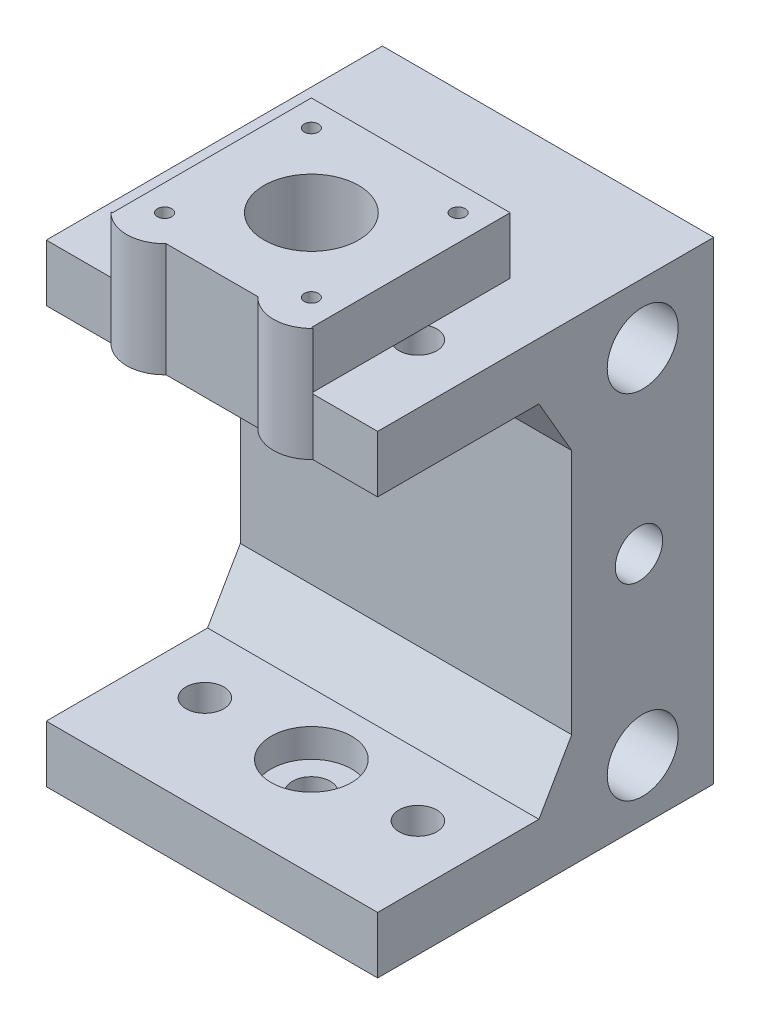
from build123d import *

# Parameters (mm, degrees)
BOSS_EXTRUDE1_DEPTH     = 35
SKETCH2_R               = 4
CUT_EXTRUDE1_DEPTH      = 101
SKETCH3_R               = 7.5
SKETCH3_R_2             = 5
CUT_EXTRUDE2_DEPTH      = 1
CUT_EXTRUDE2_DEPTH_BACK = 71
CHAMFER1_SIZE           = 12
CHAMFER1_SIZE2          = 6.92820323
CHAMFER2_SIZE           = 12
CHAMFER2_SIZE2          = 6.92820323
SKETCH4_R               = 10
CUT_EXTRUDE3_DEPTH      = 12
CUT_EXTRUDE4_START      = -18.803848
SKETCH5_R               = 1.5
CUT_EXTRUDE4_DEPTH      = 18.803848
BOSS_EXTRUDE2_DEPTH     = 12
SKETCH7_R               = 2.75
CUT_EXTRUDE5_DEPTH      = 41
SKETCH8_R               = 10
SKETCH8_R_2             = 1.5
BOSS_EXTRUDE3_DEPTH     = 12
SKETCH9_R               = 8.5
CUT_EXTRUDE6_DEPTH      = 6
SKETCH10_R              = 11
CUT_EXTRUDE7_DEPTH      = 4
SKETCH11_R              = 5
SKETCH11_R_2            = 1.1
CUT_EXTRUDE8_DEPTH      = 20


with BuildPart() as part:
    # Sketch1 → Boss-Extrude1 (new body, symmetric)
    with BuildSketch(Plane(origin=(0, 0, 0), x_dir=(0, 0, -1), z_dir=(1, 0, 0))):
        Polygon((30, 50), (30, -50), (-41, -50), (-41, -38), (0, -38), (0, 38), (-41, 38), (-41, 50), align=None)
    extrude(amount=BOSS_EXTRUDE1_DEPTH, both=True)

    # Sketch2 → Cut-Extrude1 (cut, through all)
    with BuildSketch(Plane(origin=(0, 50, 0), x_dir=(1, 0, 0), z_dir=(0, 1, 0))):
        with Locations((-22.5, -20)):
            Circle(SKETCH2_R)
        with Locations((22.5, -20)):
            Circle(SKETCH2_R)
        with Locations((0, -20)):
            Circle(SKETCH2_R)
    extrude(amount=-CUT_EXTRUDE1_DEPTH, mode=Mode.SUBTRACT)

    # Sketch3 → Cut-Extrude2 (cut, two sides)
    with BuildSketch(Plane(origin=(35, 0, 0), x_dir=(0, 0, -1), z_dir=(1, 0, 0))) as cut_extrude2_sk:
        with Locations((15, -37.25)):
            Circle(SKETCH3_R)
        with Locations((15, 37.25)):
            Circle(SKETCH3_R)
        with Locations((14.2, 0)):
            Circle(SKETCH3_R_2)
    extrude(amount=CUT_EXTRUDE2_DEPTH, mode=Mode.SUBTRACT)
    extrude(cut_extrude2_sk.sketch, amount=-CUT_EXTRUDE2_DEPTH_BACK, mode=Mode.SUBTRACT)

    # Chamfer1
    chamfer1_edges = [part.edges().sort_by_distance(p)[0] for p in [
        (0, -38, 0),
    ]]
    chamfer1_side = [part.faces().sort_by_distance(p)[0] for p in [
        (0, 0, 0),
    ]]
    chamfer(chamfer1_edges, length=CHAMFER1_SIZE, length2=CHAMFER1_SIZE2, reference=chamfer1_side[0])

    # Chamfer2
    chamfer2_edges = [part.edges().sort_by_distance(p)[0] for p in [
        (0, 38, 0),
    ]]
    chamfer2_side = [part.faces().sort_by_distance(p)[0] for p in [
        (0, 6, 0),
    ]]
    chamfer(chamfer2_edges, length=CHAMFER2_SIZE, length2=CHAMFER2_SIZE2, reference=chamfer2_side[0])

    # Sketch4 → Cut-Extrude3 (cut)
    with BuildSketch(Plane(origin=(0, 50, 0), x_dir=(1, 0, 0), z_dir=(0, 1, 0))):
        with Locations((0, -20)):
            Circle(SKETCH4_R)
    extrude(amount=-CUT_EXTRUDE3_DEPTH, mode=Mode.SUBTRACT)

    # Sketch5 → Cut-Extrude4 (cut)
    with BuildSketch(Plane(origin=(0, 50, 0), x_dir=(1, 0, 0), z_dir=(0, 1, 0)).offset(CUT_EXTRUDE4_START)):
        with Locations((15.5, -4.5)):
            Circle(SKETCH5_R)
        with Locations((-15.5, -4.5)):
            Circle(SKETCH5_R)
        with Locations((15.5, -35.5)):
            Circle(SKETCH5_R)
        with Locations((-15.5, -35.5)):
            Circle(SKETCH5_R)
    extrude(amount=CUT_EXTRUDE4_DEPTH, mode=Mode.SUBTRACT)

    # Sketch6 → Boss-Extrude2 (add, symmetric)
    with BuildSketch(Plane(origin=(0, 50, 0), x_dir=(1, 0, 0), z_dir=(0, 1, 0))):
        with BuildLine():
            Line((-21.309475019, -41), (-9.690524981, -41))
            ThreePointArc((-9.690524981, -41), (-15.5, -43.5), (-21.309475019, -41))
        make_face()
        with BuildLine():
            Line((21.309475019, -41), (9.690524981, -41))
            ThreePointArc((9.690524981, -41), (15.5, -43.5), (21.309475019, -41))
        make_face()
    extrude(amount=BOSS_EXTRUDE2_DEPTH, both=True)

    # Sketch7 → Cut-Extrude5 (cut)
    with BuildSketch(Plane(origin=(0, 0, 0), x_dir=(1, 0, 0), z_dir=(0, 1, 0))):
        with Locations((15.5, -4.5)):
            Circle(SKETCH7_R)
        with Locations((-15.5, -4.5)):
            Circle(SKETCH7_R)
        with Locations((15.5, -35.5)):
            Circle(SKETCH7_R)
        with Locations((-15.5, -35.5)):
            Circle(SKETCH7_R)
    extrude(amount=CUT_EXTRUDE5_DEPTH, mode=Mode.SUBTRACT)

    # Sketch8 → Boss-Extrude3 (add)
    with BuildSketch(Plane(origin=(0, 50, 0), x_dir=(1, 0, 0), z_dir=(0, 1, 0))):
        Polygon((17.464466094, 1), (-17.464466094, 1), (-21, 1), (-21, -2.535533906), (-21, -37.464466094), (-21, -41), (-17.464466094, -41), (17.464466094, -41), (21, -41), (21, -37.464466094), (21, -2.535533906), (21, 1), align=None)
        with Locations((0, -20)):
            Circle(SKETCH8_R, mode=Mode.SUBTRACT)
        with Locations((-15.5, -35.5)):
            Circle(SKETCH8_R_2, mode=Mode.SUBTRACT)
        with Locations((15.5, -35.5)):
            Circle(SKETCH8_R_2, mode=Mode.SUBTRACT)
        with Locations((-15.5, -4.5)):
            Circle(SKETCH8_R_2, mode=Mode.SUBTRACT)
        with Locations((15.5, -4.5)):
            Circle(SKETCH8_R_2, mode=Mode.SUBTRACT)
    extrude(amount=BOSS_EXTRUDE3_DEPTH)

    # Sketch9 → Cut-Extrude6 (cut)
    with BuildSketch(Plane(origin=(0, -38, 0), x_dir=(1, 0, 0), z_dir=(0, 1, 0))):
        with Locations((0, -20)):
            Circle(SKETCH9_R)
    extrude(amount=-CUT_EXTRUDE6_DEPTH, mode=Mode.SUBTRACT)

    # Sketch10 → Cut-Extrude7 (cut)
    with BuildSketch(Plane.ZY.offset(35)):
        with Locations((-14.2, 0)):
            Circle(SKETCH10_R)
    extrude(amount=-CUT_EXTRUDE7_DEPTH, mode=Mode.SUBTRACT)

    # Sketch11 → Cut-Extrude8 (cut)
    with BuildSketch(Plane.ZY.offset(31)):
        with Locations((-14.2, 0)):
            Circle(SKETCH11_R)
        with Locations((-14.2, 8)):
            Circle(SKETCH11_R_2)
        with Locations((-6.2, 0)):
            Circle(SKETCH11_R_2)
        with Locations((-14.2, -8)):
            Circle(SKETCH11_R_2)
        with Locations((-22.2, 0)):
            Circle(SKETCH11_R_2)
    extrude(amount=-CUT_EXTRUDE8_DEPTH, mode=Mode.SUBTRACT)


solid = part.part
